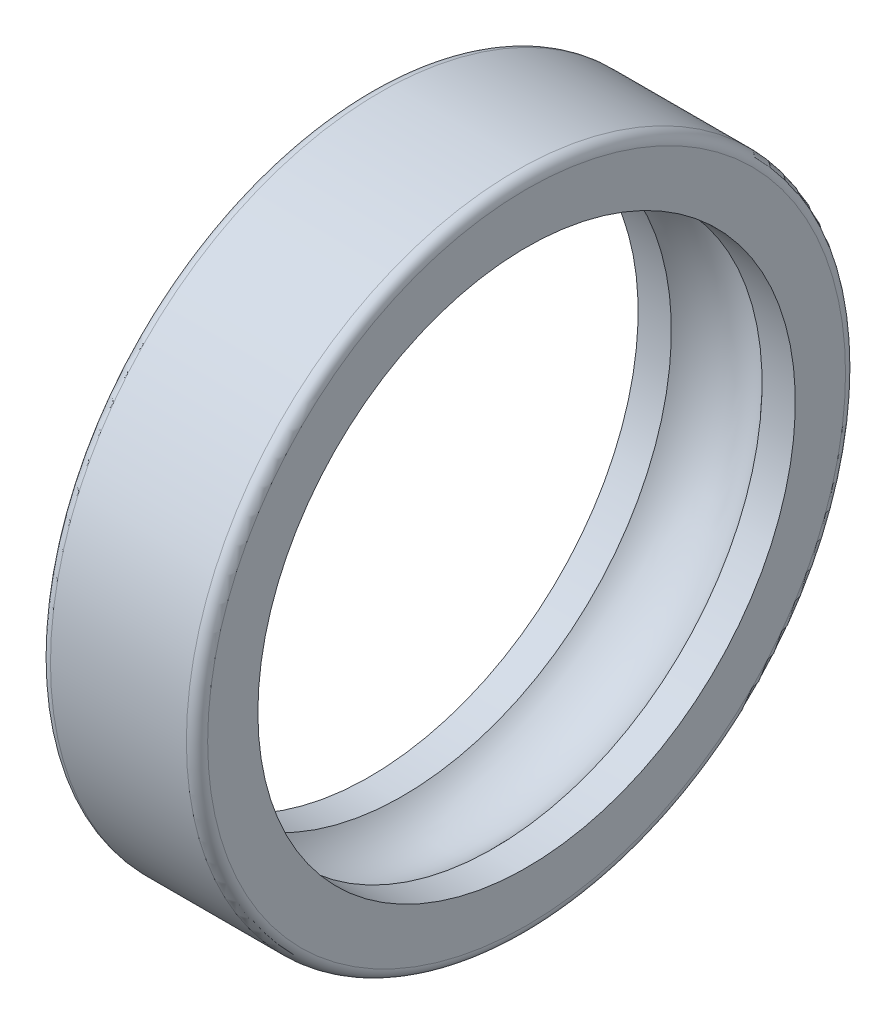
from build123d import *

# Parameters (mm, degrees)
FILLET1_R = 2.1


with BuildPart() as part:
    # Sketch1 → Revolve1 (revolve)
    with BuildSketch(Plane.XY):
        with BuildLine():
            Line((-15.5, 65), (15.5, 65))
            Line((15.5, 65), (15.5, 53))
            Line((15.5, 53), (8.94427191, 53))
            ThreePointArc((8.94427191, 53), (0, 57), (-8.94427191, 53))
            Line((-8.94427191, 53), (-15.5, 53))
            Line((-15.5, 53), (-15.5, 65))
        make_face()
    revolve(axis=Axis((-33.15505399, 0, 0), (1, 0, 0)))

    # Fillet1
    fillet1_edges = [part.edges().sort_by_distance(p)[0] for p in [
        (15.5, -65, 0),
        (-15.5, -65, 0),
    ]]
    fillet(fillet1_edges, radius=FILLET1_R)


solid = part.part
